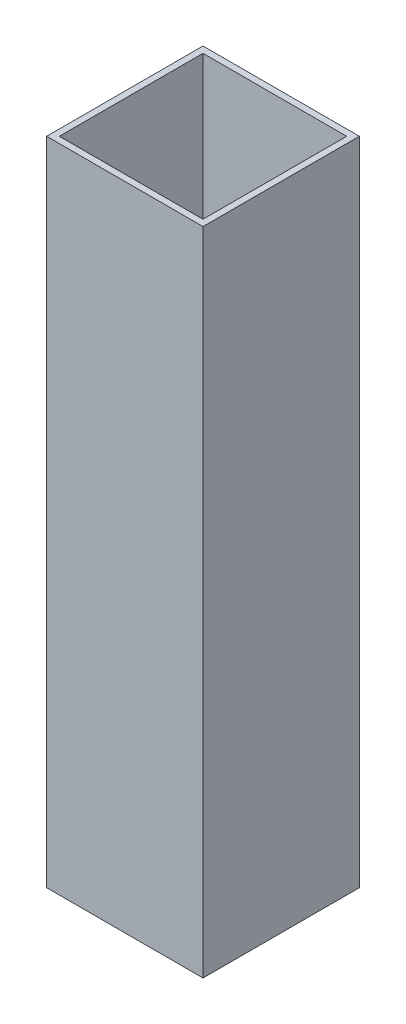
from build123d import *

# Parameters (mm, degrees)
SKETCH1_W                        = 18.796
SKETCH1_H                        = 18.796
SKETCH1_W_2                      = 17.272
SKETCH1_H_2                      = 17.272
BOSS_EXTRUDE1_DEPTH              = 76.2
SKETCH2_W                        = 18.796
SKETCH2_H                        = 18.796
BOSS_EXTRUDE2_DEPTH              = 2.032
F_10_0_1935_DIAMETER_HOLE1_D     = 4.572
F_10_0_1935_DIAMETER_HOLE1_DEPTH = 6.35
F_10_0_1935_DIAMETER_HOLE1_TIP   = 1.373567375


with BuildPart() as part:
    # Sketch1 → Boss-Extrude1 (new body)
    with BuildSketch(Plane(origin=(0, 0, 0), x_dir=(1, 0, 0), z_dir=(0, 1, 0))):
        Rectangle(SKETCH1_W, SKETCH1_H)
        Rectangle(SKETCH1_W_2, SKETCH1_H_2, mode=Mode.SUBTRACT)
    extrude(amount=BOSS_EXTRUDE1_DEPTH)

    # Sketch2 → Boss-Extrude2 (add)
    with BuildSketch(Plane.XZ):
        Rectangle(SKETCH2_W, SKETCH2_H)
    extrude(amount=BOSS_EXTRUDE2_DEPTH)

    # #10 (0.1935) Diameter Hole1
    with Locations(Plane(origin=(0, -2.032, 0), x_dir=(-1, 0, 0), z_dir=(0, -1, 0))):
        with Locations((0, 0)):
            Hole(F_10_0_1935_DIAMETER_HOLE1_D / 2, depth=F_10_0_1935_DIAMETER_HOLE1_DEPTH)
            with Locations((0, 0, -(F_10_0_1935_DIAMETER_HOLE1_DEPTH + F_10_0_1935_DIAMETER_HOLE1_TIP / 2))):  # 118° drill point
                Cone(0, F_10_0_1935_DIAMETER_HOLE1_D / 2, F_10_0_1935_DIAMETER_HOLE1_TIP, mode=Mode.SUBTRACT)


solid = part.part
